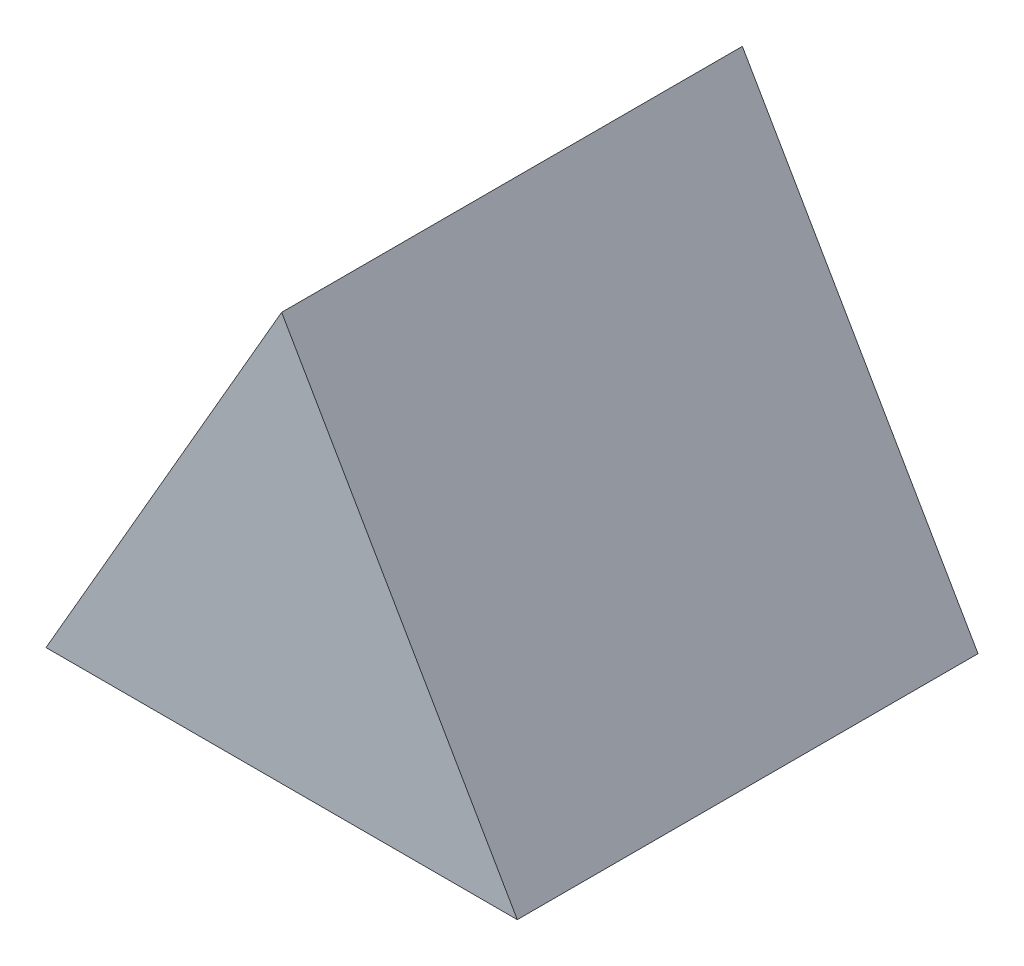
from build123d import *

# Parameters (mm, degrees)
ESTRUSIONE_ESTRUSIONE1_DEPTH = 160


with BuildPart() as part:
    # Schizzo1 → Estrusione-Estrusione1 (new body)
    with BuildSketch(Plane.XY):
        Polygon((0, 94.5), (-81.839400658, -47.25), (81.839400658, -47.25), align=None)
    extrude(amount=ESTRUSIONE_ESTRUSIONE1_DEPTH)


solid = part.part
